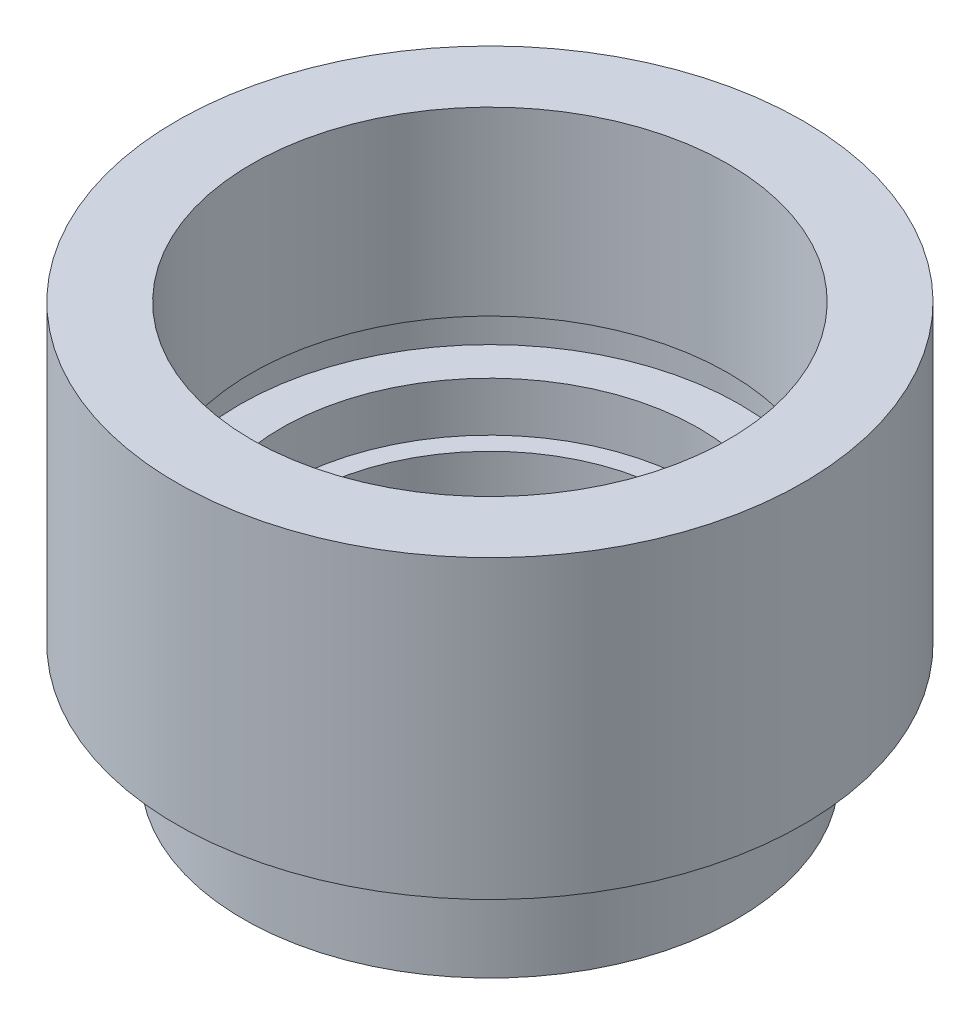
from build123d import *


with BuildPart() as part:
    # 草图1 → 旋转1 (revolve)
    with BuildSketch(Plane.XY, mode=Mode.PRIVATE) as revolve_1_sk:
        Polygon((5.75, 0), (7.5, 0), (7.5, 2.5), (7, 2.5), (7, 3.5), (9.525, 3.5), (9.525, 12.5), (7.25, 12.5), (7.25, 7), (7.6, 7), (7.6, 6), (6.35, 6), (6.35, 4.5), (5.75, 4.5), align=None)
    revolve(revolve_1_sk.sketch.rotate(Axis((0, 0, 0), (0, 1, 0)), 90), axis=Axis((0, 0, 0), (0, 1, 0)))  # turned: the seam where the file's is


solid = part.part
